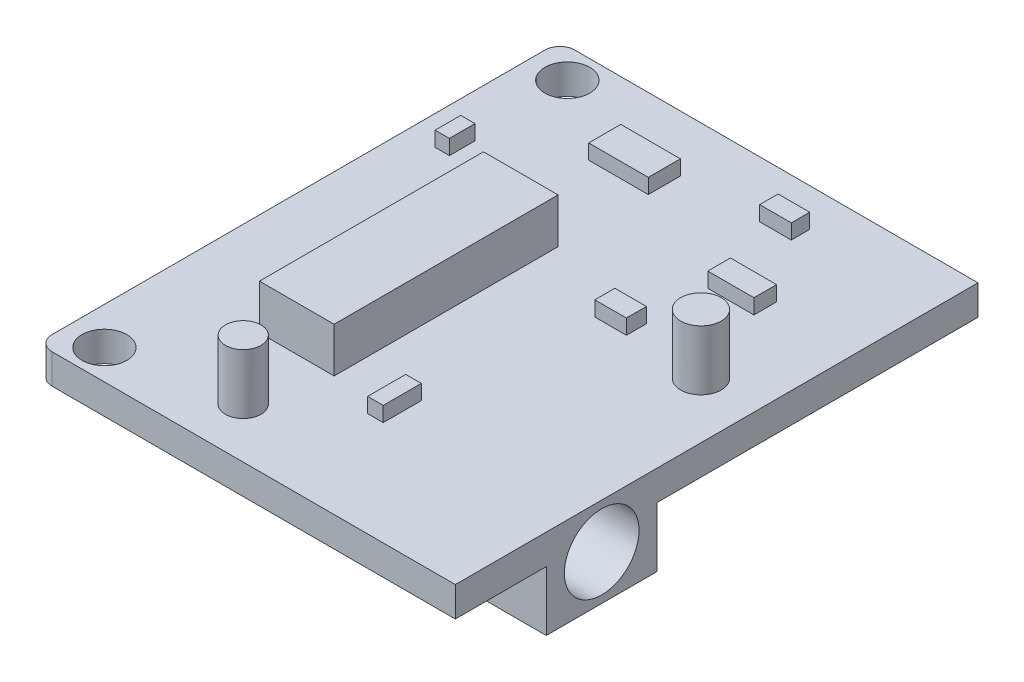
from build123d import *

# Parameters (mm, degrees)
SKETCH1_W           = 28
SKETCH1_H           = 35
SKETCH1_R           = 1.5
BOSS_EXTRUDE1_DEPTH = 2
SKETCH2_W           = 9.803487011
SKETCH2_H           = 7.411177961
BOSS_EXTRUDE2_DEPTH = 6
SKETCH2_3_W         = 5
SKETCH2_3_H         = 15
BOSS_EXTRUDE3_DEPTH = 3
SKETCH2_4_R         = 1.188771684
SKETCH2_4_R_2       = 1.358321726
BOSS_EXTRUDE4_DEPTH = 4
SKETCH2_5_W         = 3.990758571
SKETCH2_5_H         = 2.149147788
SKETCH2_5_W_2       = 2.114664683
SKETCH2_5_H_2       = 1.232229244
SKETCH2_5_W_3       = 3.092189454
SKETCH2_5_H_3       = 1.517885082
SKETCH2_5_H_4       = 1.341337727
SKETCH2_5_W_4       = 1.043883653
SKETCH2_5_H_5       = 2.549502456
SKETCH2_5_W_5       = 0.955721455
SKETCH2_5_H_6       = 1.716190389
BOSS_EXTRUDE5_DEPTH = 1
FILLET1_R           = 1
SKETCH3_R           = 2.5
CUT_EXTRUDE1_DEPTH  = 6


with BuildPart() as part:
    # Sketch1 → Boss-Extrude1 (new body)
    with BuildSketch(Plane(origin=(0, 0, 0), x_dir=(1, 0, 0), z_dir=(0, 1, 0))):
        with Locations((14, 17.5)):
            Rectangle(SKETCH1_W, SKETCH1_H)
        with Locations((2.5, 2)):
            Circle(SKETCH1_R, mode=Mode.SUBTRACT)
        with Locations((2.5, 33)):
            Circle(SKETCH1_R, mode=Mode.SUBTRACT)
    extrude(amount=BOSS_EXTRUDE1_DEPTH)

    # Sketch2 → Boss-Extrude2 (add)
    with BuildSketch(Plane(origin=(0, 2, 0), x_dir=(1, 0, 0), z_dir=(0, 1, 0))):
        with Locations((23.098256494, 9.79441102)):
            Rectangle(SKETCH2_W, SKETCH2_H)
    extrude(amount=-BOSS_EXTRUDE2_DEPTH)

    # Sketch2_3 → Boss-Extrude3 (add)
    with BuildSketch(Plane(origin=(0, 2, 0), x_dir=(1, 0, 0), z_dir=(0, 1, 0))):
        with Locations((9.343972274, 15.538611718)):
            Rectangle(SKETCH2_3_W, SKETCH2_3_H)
    extrude(amount=BOSS_EXTRUDE3_DEPTH)

    # Sketch2_4 → Boss-Extrude4 (add)
    with BuildSketch(Plane(origin=(0, 2, 0), x_dir=(1, 0, 0), z_dir=(0, 1, 0))):
        with Locations((10.43268107, 3.363069922)):
            Circle(SKETCH2_4_R)
        with Locations((24.262223339, 20.185094641)):
            Circle(SKETCH2_4_R_2)
    extrude(amount=BOSS_EXTRUDE4_DEPTH)

    # Sketch2_5 → Boss-Extrude5 (add)
    with BuildSketch(Plane(origin=(0, 2, 0), x_dir=(1, 0, 0), z_dir=(0, 1, 0))):
        with Locations((9.848592989, 30.151261091)):
            Rectangle(SKETCH2_5_W, SKETCH2_5_H)
        with Locations((18.212826519, 31.841949607)):
            Rectangle(SKETCH2_5_W_2, SKETCH2_5_H_2)
        with Locations((20.816253587, 26.392524838)):
            Rectangle(SKETCH2_5_W_3, SKETCH2_5_H_3)
        with Locations((18.212826519, 20.855763505)):
            Rectangle(SKETCH2_5_W_2, SKETCH2_5_H_4)
        with Locations((15.671715961, 8.251316283)):
            Rectangle(SKETCH2_5_W_4, SKETCH2_5_H_5)
        with Locations((2.447985743, 25.534429644)):
            Rectangle(SKETCH2_5_W_5, SKETCH2_5_H_6)
    extrude(amount=BOSS_EXTRUDE5_DEPTH)

    # Fillet1
    fillet1_edges = [part.edges().sort_by_distance(p)[0] for p in [
        (0, 1, 0),
        (0, 1, -35),
    ]]
    fillet(fillet1_edges, radius=FILLET1_R)

    # Sketch3 → Cut-Extrude1 (cut)
    with BuildSketch(Plane(origin=(28, 0, 0), x_dir=(0, 0, -1), z_dir=(1, 0, 0))):
        with Locations((9.8, -1)):
            Circle(SKETCH3_R)
    extrude(amount=-CUT_EXTRUDE1_DEPTH, mode=Mode.SUBTRACT)


solid = part.part
